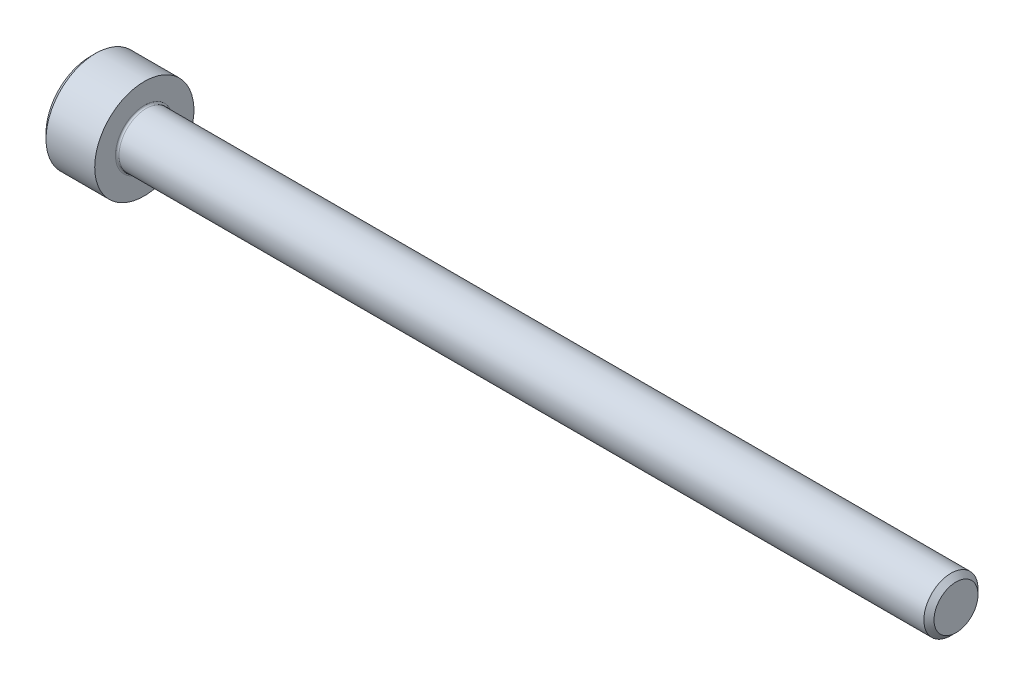
from build123d import *

# Parameters (mm, degrees)
FILLET1_R   = 0.1
HEX_2_DEPTH = 1.3


with BuildPart() as part:
    # BodySke → Base-Revolve (revolve)
    with BuildSketch(Plane.XY):
        Polygon((0, 0), (0, 2.45), (0.3, 2.75), (3, 2.75), (3, 1.5), (47.7195, 1.5), (48, 1.2195), (48, 0), align=None)
    revolve(axis=Axis((-31.75, 0, 0), (1, 0, 0)))

    # Fillet1
    fillet1_edges = [part.edges().sort_by_distance(p)[0] for p in [
        (3, -1.5, 0),
    ]]
    fillet(fillet1_edges, radius=FILLET1_R)

    # Sketch2 → Hex-PreBroach (revolve, cut)
    with BuildSketch(Plane.XY):
        Polygon((0, 1.28), (1.3, 1.28), (2.039008345, 0), (0, 0), align=None)
    revolve(axis=Axis((0, 0, 0), (1, 0, 0)), mode=Mode.SUBTRACT)

    # Sketch3 → Hex 2 (cut)
    with BuildSketch(Plane(origin=(0, 0, 0), x_dir=(0, 0.5, 0.866025404), z_dir=(-1, 0, 0))):
        Polygon((0.739008345, 1.28), (-0.739008345, 1.28), (-1.478016689, 0), (-0.739008345, -1.28), (0.739008345, -1.28), (1.478016689, 0), align=None)
    extrude(amount=-HEX_2_DEPTH, mode=Mode.SUBTRACT)


solid = part.part
